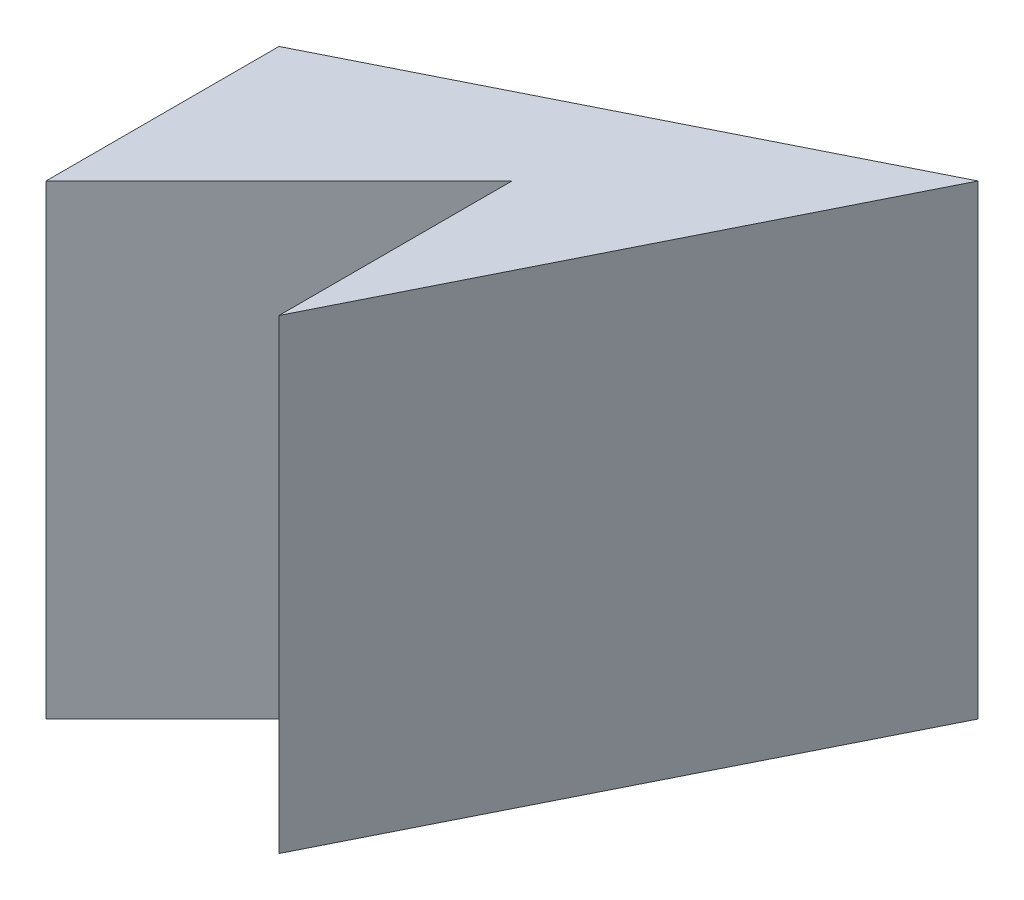
from build123d import *

# Parameters (mm, degrees)
BOSS_EXTRUDE2_DEPTH = 4


with BuildPart() as part:
    # Sketch2 → Boss-Extrude2 (new body)
    with BuildSketch(Plane(origin=(0, 0, 0), x_dir=(1, 0, 0), z_dir=(0, 1, 0))):
        Polygon((0, 0), (0, 2), (-2, 0), (-2, 2), (2, 4), align=None)
    extrude(amount=BOSS_EXTRUDE2_DEPTH)


solid = part.part
